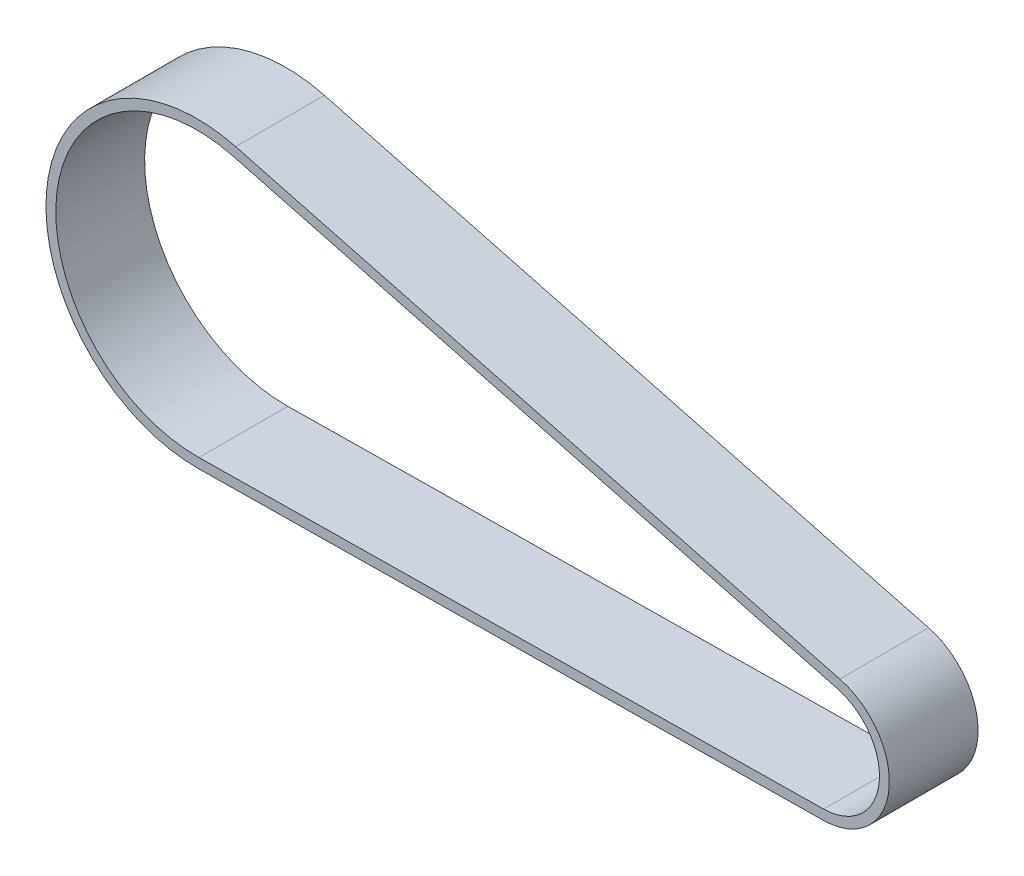
from build123d import *

# Parameters (mm, degrees)
EXTRUDE_THIN1_DEPTH      = 4.5
EXTRUDE_THIN1_DEPTH_BACK = 4.5


with BuildPart() as part:
    # Sketch2 → Extrude-Thin1 (new, two sides)
    with BuildSketch(Plane.XY) as extrude_thin1_sk:
        with BuildLine():
            Line((-59.532286985, 22.625267911), (1.712714455, 6.508418333))
            ThreePointArc((1.712714455, 6.508418333), (6.679691158, -0.821356217), (0.084942055, -6.729463935))
            Line((0.084942055, -6.729463935), (-63.240125155, -7.528778918))
            ThreePointArc((-63.240125155, -7.528778918), (-78.649014777, 9.670934742), (-59.532286985, 22.625267911))
        make_face()
        with BuildLine():
            Line((-59.786776502, 21.658192379), (1.458224937, 5.5413428))
            ThreePointArc((1.458224937, 5.5413428), (5.687166469, -0.699312203), (0.07232065, -5.729543588))
            Line((0.07232065, -5.729543588), (-63.25274656, -6.528858571))
            ThreePointArc((-63.25274656, -6.528858571), (-77.656490088, 9.548890728), (-59.786776502, 21.658192379))
        make_face(mode=Mode.SUBTRACT)
    extrude(amount=EXTRUDE_THIN1_DEPTH)
    extrude(extrude_thin1_sk.sketch, amount=-EXTRUDE_THIN1_DEPTH_BACK)


solid = part.part
